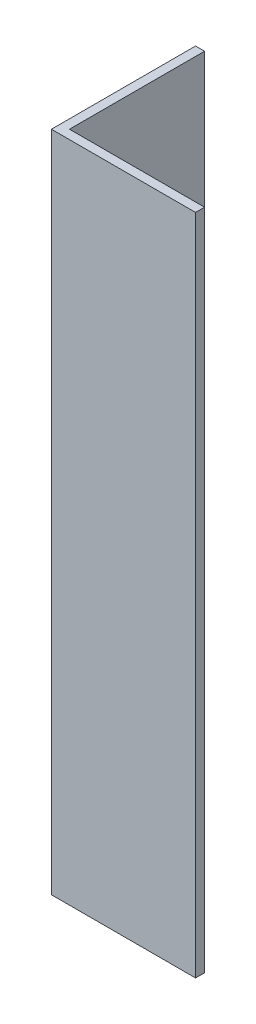
from build123d import *

# Parameters (mm, degrees)
BOSS_EXTRUDE1_DEPTH = 116.84


with BuildPart() as part:
    # Sketch1 → Boss-Extrude1 (new body)
    with BuildSketch(Plane(origin=(0, 0, 0), x_dir=(1, 0, 0), z_dir=(0, 1, 0))):
        Polygon((0, 0), (0, 25.4), (1.5875, 25.4), (1.5875, 1.5875), (25.4, 1.5875), (25.4, 0), align=None)
    extrude(amount=BOSS_EXTRUDE1_DEPTH)


solid = part.part
